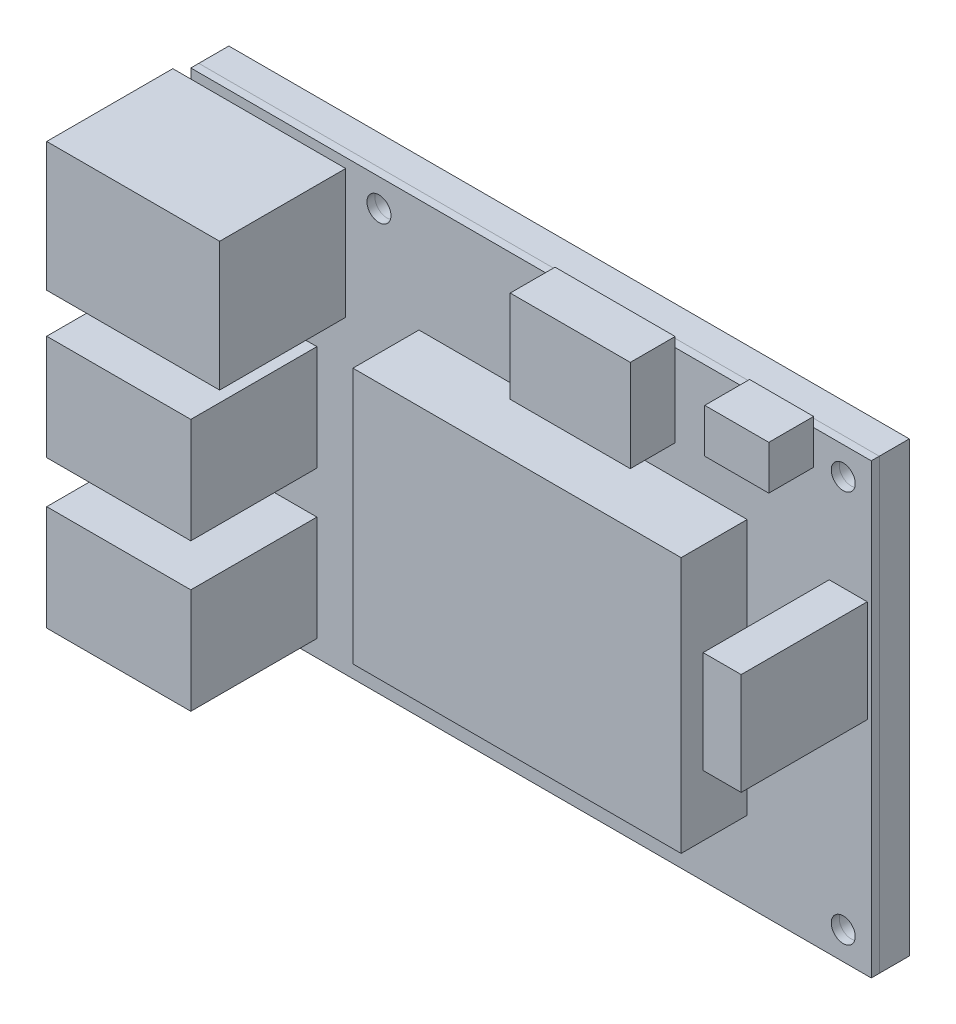
from build123d import *

# Parameters (mm, degrees)
SKETCH1_W                         = 85
SKETCH1_H                         = 55.95
SKETCH1_R                         = 1.5
BOSS_EXTRUDE1_DEPTH               = 1
SKETCH1_2_W                       = 85
SKETCH1_2_H                       = 55.95
SKETCH1_2_R                       = 1.5
BOSS_EXTRUDE2_LOWER_KEEPOUT_DEPTH = 3.75
SKETCH3_W                         = 41
SKETCH3_H                         = 32
BOSS_EXTRUDE3_DEPTH               = 8.25
SKETCH4_W                         = 18
SKETCH4_H                         = 13.14
SKETCH4_W_2                       = 4.755
SKETCH4_H_2                       = 12.75
SKETCH4_W_3                       = 21.6
SKETCH4_H_3                       = 16.1
BOSS_EXTRUDE4_DEPTH               = 15.75
SKETCH5_W                         = 15
SKETCH5_H                         = 11.5
SKETCH5_W_2                       = 8
SKETCH5_H_2                       = 5.5
BOSS_EXTRUDE5_DEPTH               = 5.6
SKETCH6_W                         = 11.61
SKETCH6_H                         = 15.75
BOSS_EXTRUDE6_DEPTH               = 4


with BuildPart() as part:
    # Sketch1 → Boss-Extrude1 (new body)
    with BuildSketch(Plane.XY):
        Rectangle(SKETCH1_W, SKETCH1_H)
        with Locations((-19.000000078, 24.5)):
            Circle(SKETCH1_R, mode=Mode.SUBTRACT)
        with Locations((-19.000000078, -24.5)):
            Circle(SKETCH1_R, mode=Mode.SUBTRACT)
        with Locations((39, 24.5)):
            Circle(SKETCH1_R, mode=Mode.SUBTRACT)
        with Locations((39, -24.5)):
            Circle(SKETCH1_R, mode=Mode.SUBTRACT)
    extrude(amount=BOSS_EXTRUDE1_DEPTH)

    # Sketch3 → Boss-Extrude3 (add)
    with BuildSketch(Plane.XY.offset(1)):
        with Locations((6.5, -2.125)):
            Rectangle(SKETCH3_W, SKETCH3_H)
    extrude(amount=BOSS_EXTRUDE3_DEPTH)

    # Sketch4 → Boss-Extrude4 (add)
    with BuildSketch(Plane.XY.offset(1)):
        with Locations((-35.74947609, -0.865)):
            Rectangle(SKETCH4_W, SKETCH4_H)
        with Locations((-35.74947609, -19.305)):
            Rectangle(SKETCH4_W, SKETCH4_H)
        with Locations((39.6225, 6.1)):
            Rectangle(SKETCH4_W_2, SKETCH4_H_2)
        with Locations((-33.94947609, 18.725)):
            Rectangle(SKETCH4_W_3, SKETCH4_H_3)
    extrude(amount=BOSS_EXTRUDE4_DEPTH)

    # Sketch5 → Boss-Extrude5 (add)
    with BuildSketch(Plane.XY.offset(1)):
        with Locations((10.5, 23.425)):
            Rectangle(SKETCH5_W, SKETCH5_H)
        with Locations((31.3, 26.425)):
            Rectangle(SKETCH5_W_2, SKETCH5_H_2)
    extrude(amount=BOSS_EXTRUDE5_DEPTH)


with BuildPart() as body_2:
    # Sketch1_2 → Boss-Extrude2-lower-keepout (new body)
    with BuildSketch(Plane.XY):
        Rectangle(SKETCH1_2_W, SKETCH1_2_H)
        with Locations((-19.000000078, 24.5)):
            Circle(SKETCH1_2_R, mode=Mode.SUBTRACT)
        with Locations((-19.000000078, -24.5)):
            Circle(SKETCH1_2_R, mode=Mode.SUBTRACT)
        with Locations((39, 24.5)):
            Circle(SKETCH1_2_R, mode=Mode.SUBTRACT)
        with Locations((39, -24.5)):
            Circle(SKETCH1_2_R, mode=Mode.SUBTRACT)
    extrude(amount=-BOSS_EXTRUDE2_LOWER_KEEPOUT_DEPTH)


with BuildPart() as body_3:
    # Sketch6 → Boss-Extrude6 (new body)
    with BuildSketch(Plane.XY):
        with Locations((-6.401910681, -20.6)):
            Rectangle(SKETCH6_W, SKETCH6_H)
    extrude(amount=-BOSS_EXTRUDE6_DEPTH)


solid = Compound([part.part, body_2.part, body_3.part])
